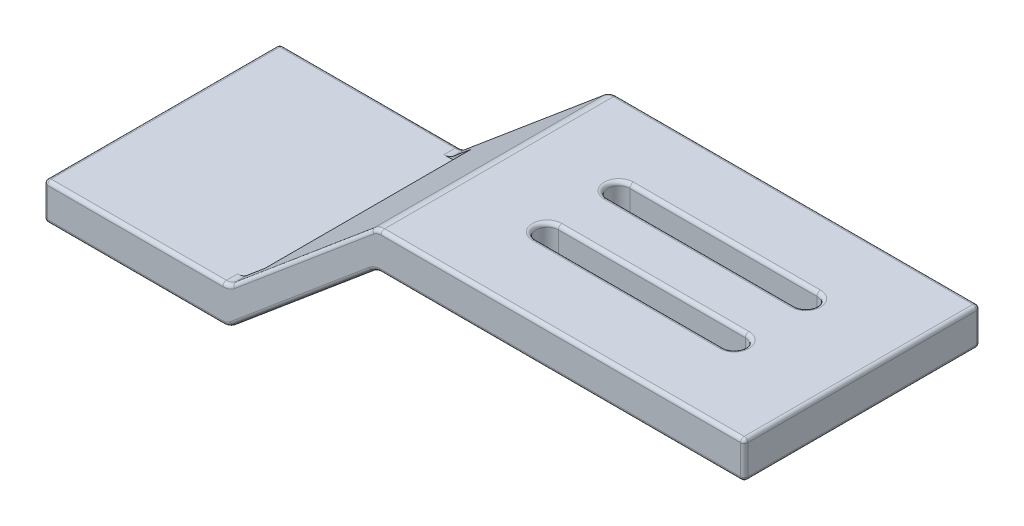
from build123d import *

# Parameters (mm, degrees)
SKETCH_1_W          = 25
SKETCH_1_H          = 5
EXTRUDE_1_DEPTH     = 32
SKETCH_2_W          = 50
SKETCH_2_H          = 5
EXTRUDE_2_DEPTH     = 32
FILLET_1_R          = 2
CUT_EXTRUDE_1_DEPTH = 10
FILLET_2_R          = 0.5
SKETCH_4_W          = 28
SKETCH_4_H          = 28
CUT_EXTRUDE_2_DEPTH = 10


with BuildPart() as part:
    # 草图1 → 凸台-拉伸1 (new body)
    with BuildSketch(Plane.XY):
        with Locations((12.5, 2.5)):
            Rectangle(SKETCH_1_W, SKETCH_1_H)
    extrude(amount=EXTRUDE_1_DEPTH)

    # 草图2 → 凸台-拉伸2 (add)
    with BuildSketch(Plane.XY.offset(32)):
        Polygon((25, 0), (45, 16.781992624), (45, 21.781992624), (25, 5), align=None)
        with Locations((70, 19.281992624)):
            Rectangle(SKETCH_2_W, SKETCH_2_H)
    extrude(amount=-EXTRUDE_2_DEPTH)

    # 圆角1
    fillet_1_edges = [part.edges().sort_by_distance(p)[0] for p in [
        (45, 21.781992624, 16),
        (45, 16.781992624, 16),
        (25, 5, 16),
        (25, 0, 16),
    ]]
    fillet(fillet_1_edges, radius=FILLET_1_R)

    # 草图3 → 切除-拉伸1 (cut)
    with BuildSketch(Plane(origin=(152.063701671, 21.781992624, 93.124397085), x_dir=(0, 0, -1), z_dir=(0, 1, 0))):
        with BuildLine():
            Line((70.768866217, 94.92997475), (70.768866217, 69.563701671))
            ThreePointArc((70.768866217, 69.563701671), (72.268866217, 68.063701671), (73.768866217, 69.563701671))
            Line((73.768866217, 69.563701671), (73.768866217, 94.92997475))
            ThreePointArc((73.768866217, 94.92997475), (72.268866217, 96.42997475), (70.768866217, 94.92997475))
        make_face()
        with BuildLine():
            Line((83.479927953, 69.563701671), (83.479927953, 94.92997475))
            ThreePointArc((83.479927953, 94.92997475), (81.979927953, 96.42997475), (80.479927953, 94.92997475))
            Line((80.479927953, 94.92997475), (80.479927953, 69.563701671))
            ThreePointArc((80.479927953, 69.563701671), (81.979927953, 68.063701671), (83.479927953, 69.563701671))
        make_face()
    extrude(amount=-CUT_EXTRUDE_1_DEPTH, mode=Mode.SUBTRACT)

    # 圆角2
    fillet_2_edges = [part.edges().sort_by_distance(p)[0] for p in [
        (95, 19.281992624, 32),
        (95, 16.781992624, 16),
        (95, 19.281992624, 0),
        (95, 21.781992624, 16),
        (70.363970234, 21.781992624, 0),
        (70.363970234, 21.781992624, 32),
        (35, 8.390996312, 32),
        (70.363970234, 16.781992624, 32),
        (35, 13.390996312, 32),
        (12.136029766, 5, 32),
        (24.956099818, 0.120614758, 32),
        (45.043900182, 21.661377865, 32),
        (35, 13.390996312, 0),
        (12.136029766, 5, 0),
        (70.363970234, 16.781992624, 0),
        (35, 8.390996312, 0),
        (24.956099818, 0.120614758, 0),
        (45.043900182, 21.661377865, 0),
        (0, 2.5, 32),
        (24.956099818, 5.120614758, 0),
        (24.956099818, 5.120614758, 32),
        (45.043900182, 16.661377865, 32),
        (45.043900182, 16.661377865, 0),
        (12.136029766, 0, 0),
        (0, 2.5, 0),
        (84, 16.781992624, 20.855530868),
        (69.81686346, 16.781992624, 22.355530868),
        (55.633726921, 16.781992624, 20.855530868),
        (69.81686346, 16.781992624, 19.355530868),
        (84, 21.781992624, 20.855530868),
        (69.81686346, 21.781992624, 19.355530868),
        (55.633726921, 21.781992624, 20.855530868),
        (69.81686346, 21.781992624, 22.355530868),
        (12.136029766, 0, 32),
        (84, 16.781992624, 11.144469132),
        (69.81686346, 16.781992624, 12.644469132),
        (55.633726921, 16.781992624, 11.144469132),
        (0, 5, 16),
        (69.81686346, 16.781992624, 9.644469132),
        (84, 21.781992624, 11.144469132),
        (69.81686346, 21.781992624, 9.644469132),
        (55.633726921, 21.781992624, 11.144469132),
        (69.81686346, 21.781992624, 12.644469132),
        (0, 0, 16),
    ]]
    fillet(fillet_2_edges, radius=FILLET_2_R)

    # 草图4 → 切除-拉伸2 (cut)
    with BuildSketch(Plane(origin=(0, 5, 0), x_dir=(1, 0, 0), z_dir=(0, 1, 0))):
        with Locations((14, -16)):
            Rectangle(SKETCH_4_W, SKETCH_4_H)
    extrude(amount=CUT_EXTRUDE_2_DEPTH, mode=Mode.SUBTRACT)


solid = part.part
